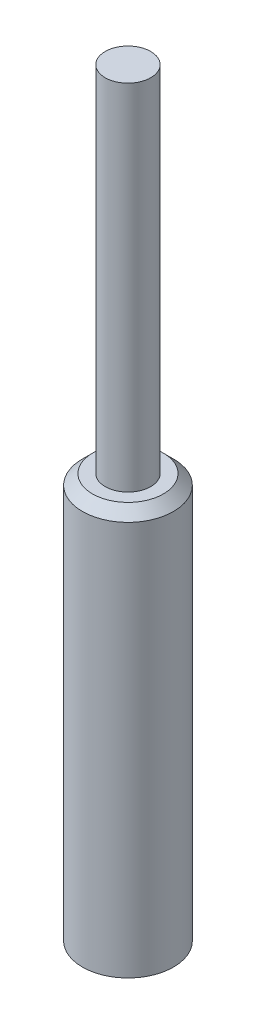
from build123d import *

# Parameters (mm, degrees)
CHAMFER_1_SIZE = 0.2


with BuildPart() as part:
    # Эскиз1 → Повернуть1 (revolve)
    with BuildSketch(Plane.XY):
        Polygon((0, 0), (-0.9, 0), (-0.9, 8), (-0.45, 8), (-0.45, 15), (0, 15), align=None)
    revolve(axis=Axis((0, 0, 0), (0, -1, 0)))

    # Фаска1
    chamfer_1_edges = [part.edges().sort_by_distance(p)[0] for p in [
        (0.9, 8, 0),
    ]]
    chamfer(chamfer_1_edges, length=CHAMFER_1_SIZE)


solid = part.part
